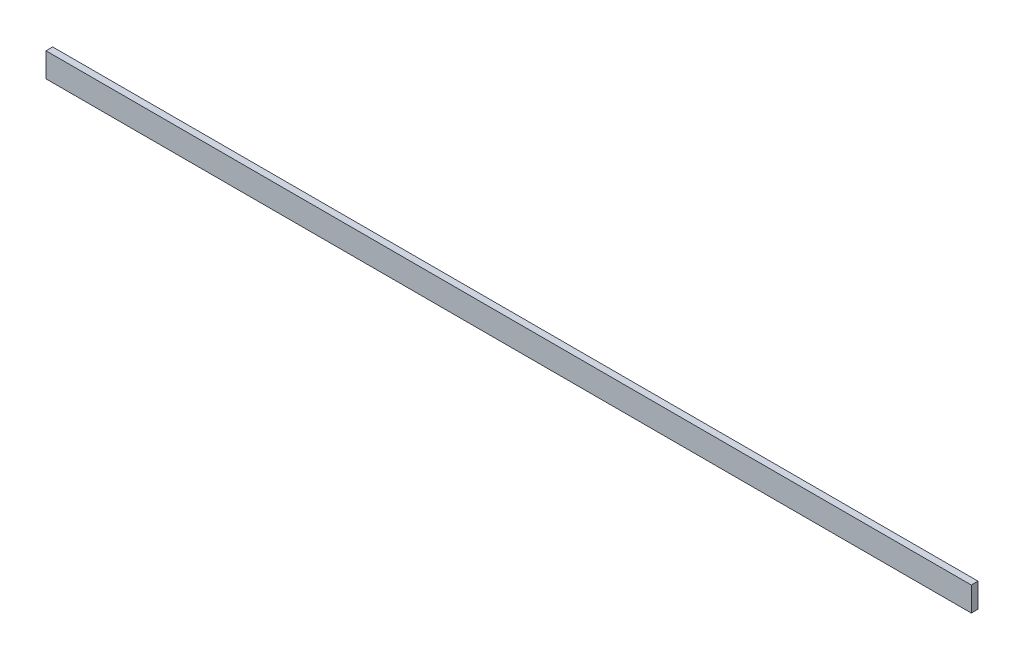
from build123d import *

# Parameters (mm, degrees)
ESQUISSE1_W      = 3044
ESQUISSE1_H      = 80
EXTRUSION1_DEPTH = 22


with BuildPart() as part:
    # Esquisse1 → Extrusion1 (new body)
    with BuildSketch(Plane.XY):
        with Locations((1522, 40)):
            Rectangle(ESQUISSE1_W, ESQUISSE1_H)
    extrude(amount=EXTRUSION1_DEPTH)


solid = part.part
